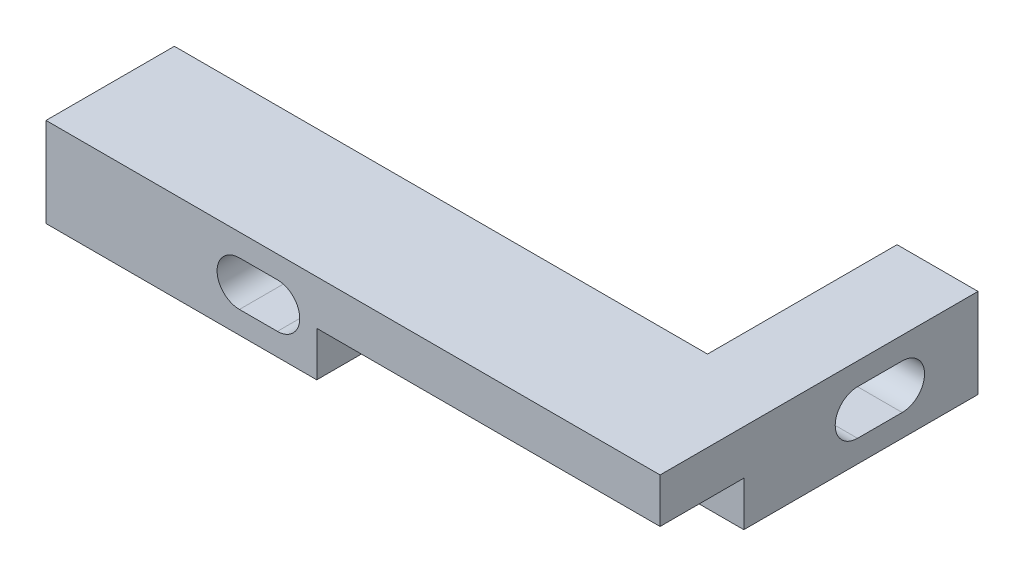
from build123d import *

# Parameters (mm, degrees)
SKETCH1_W                = 55
SKETCH1_H                = 25
BOSS_EXTRUDE1_DEPTH      = 4
SKETCH5_W                = 40.5
SKETCH5_H                = 17
CUT_EXTRUDE2_DEPTH       = 5
SKETCH6_W                = 55
SKETCH6_H                = 4.025345596
CUT_EXTRUDE3_DEPTH       = 5
SKETCH13_W               = 7.25
SKETCH13_H               = 20.974654404
BOSS_EXTRUDE3_DEPTH      = 8
SKETCH16_W               = 7.25
SKETCH16_H               = 20.974654404
BOSS_EXTRUDE4_DEPTH      = 8
SKETCH19_W               = 17
SKETCH19_H               = 4
BOSS_EXTRUDE5_DEPTH      = 4
SKETCH30_W               = 55
SKETCH30_H               = 4
BOSS_EXTRUDE6_DEPTH      = 7.5
SKETCH31_W               = 24.25
SKETCH31_H               = 4
BOSS_EXTRUDE7_DEPTH      = 7.5
SKETCH21_W               = 7.25
SKETCH21_H               = 16.974654404
CUT_EXTRUDE7_DEPTH       = 9
CUT_EXTRUDE9_DEPTH       = 56
CUT_EXTRUDE14_DEPTH      = 8.5
CUT_EXTRUDE14_DEPTH_BACK = 21.974654404


with BuildPart() as part:
    # Sketch1 → Boss-Extrude1 (new body)
    with BuildSketch(Plane(origin=(0, 0, 0), x_dir=(1, 0, 0), z_dir=(0, 1, 0))):
        Rectangle(SKETCH1_W, SKETCH1_H)
    extrude(amount=BOSS_EXTRUDE1_DEPTH)

    # Sketch5 → Cut-Extrude2 (cut, through all)
    with BuildSketch(Plane(origin=(0, 4, 0), x_dir=(1, 0, 0), z_dir=(0, 1, 0))):
        Rectangle(SKETCH5_W, SKETCH5_H)
    extrude(amount=-CUT_EXTRUDE2_DEPTH, mode=Mode.SUBTRACT)

    # Sketch6 → Cut-Extrude3 (cut, through all)
    with BuildSketch(Plane(origin=(0, 4, 0), x_dir=(1, 0, 0), z_dir=(0, 1, 0))):
        with Locations((0, 10.487327202)):
            Rectangle(SKETCH6_W, SKETCH6_H)
    extrude(amount=-CUT_EXTRUDE3_DEPTH, mode=Mode.SUBTRACT)

    # Sketch13 → Boss-Extrude3 (add)
    with BuildSketch(Plane(origin=(0, 4, 0), x_dir=(1, 0, 0), z_dir=(0, 1, 0))):
        with Locations((23.875, -2.012672798)):
            Rectangle(SKETCH13_W, SKETCH13_H)
    extrude(amount=-BOSS_EXTRUDE3_DEPTH)

    # Sketch16 → Boss-Extrude4 (add)
    with BuildSketch(Plane(origin=(0, 4, 0), x_dir=(1, 0, 0), z_dir=(0, 1, 0))):
        with Locations((-23.875, -2.012672798)):
            Rectangle(SKETCH16_W, SKETCH16_H)
    extrude(amount=-BOSS_EXTRUDE4_DEPTH)

    # Sketch19 → Boss-Extrude5 (add)
    with BuildSketch(Plane.XZ):
        with Locations((11.75, 10.5)):
            Rectangle(SKETCH19_W, SKETCH19_H)
    extrude(amount=BOSS_EXTRUDE5_DEPTH)

    # Sketch30 → Boss-Extrude6 (add)
    with BuildSketch(Plane.XY.offset(12.5)):
        with Locations((0, 2)):
            Rectangle(SKETCH30_W, SKETCH30_H)
    extrude(amount=BOSS_EXTRUDE6_DEPTH)

    # Sketch31 → Boss-Extrude7 (add)
    with BuildSketch(Plane.XY.offset(12.5)):
        with Locations((15.375, -2)):
            Rectangle(SKETCH31_W, SKETCH31_H)
    extrude(amount=BOSS_EXTRUDE7_DEPTH)

    # Sketch21 → Cut-Extrude7 (cut, through all)
    with BuildSketch(Plane(origin=(0, 4, 0), x_dir=(1, 0, 0), z_dir=(0, 1, 0))):
        with Locations((23.875, -0.012672798)):
            Rectangle(SKETCH21_W, SKETCH21_H)
    extrude(amount=-CUT_EXTRUDE7_DEPTH, mode=Mode.SUBTRACT)

    # Sketch25 → Cut-Extrude9 (cut, through all)
    with BuildSketch(Plane.ZY.offset(27.5)):
        with BuildLine():
            Line((2.314549123, -2), (-1.685450877, -2))
            ThreePointArc((-1.685450877, -2), (-3.685450877, 0), (-1.685450877, 2))
            Line((-1.685450877, 2), (2.314549123, 2))
            ThreePointArc((2.314549123, 2), (4.314549123, 0), (2.314549123, -2))
        make_face()
    extrude(amount=-CUT_EXTRUDE9_DEPTH, mode=Mode.SUBTRACT)

    # Sketch29 → Cut-Extrude14 (cut, two sides)
    with BuildSketch(Plane.XY.offset(12.5)) as cut_extrude14_sk:
        with BuildLine():
            Line((6.774762471, 2), (10.174762471, 2))
            ThreePointArc((10.174762471, 2), (12.174762471, 0), (10.174762471, -2))
            Line((10.174762471, -2), (6.774762471, -2))
            ThreePointArc((6.774762471, -2), (4.774762471, 0), (6.774762471, 2))
        make_face()
    extrude(amount=CUT_EXTRUDE14_DEPTH, mode=Mode.SUBTRACT)
    extrude(cut_extrude14_sk.sketch, amount=-CUT_EXTRUDE14_DEPTH_BACK, mode=Mode.SUBTRACT)


with BuildPart() as body_2:
    # Mirror1: mirrored copy
    add(part.part.mirror(Plane(origin=(27.5, 0, 14.25), x_dir=(0, 0, 1), z_dir=(1, 0, 0))))


solid = body_2.part
